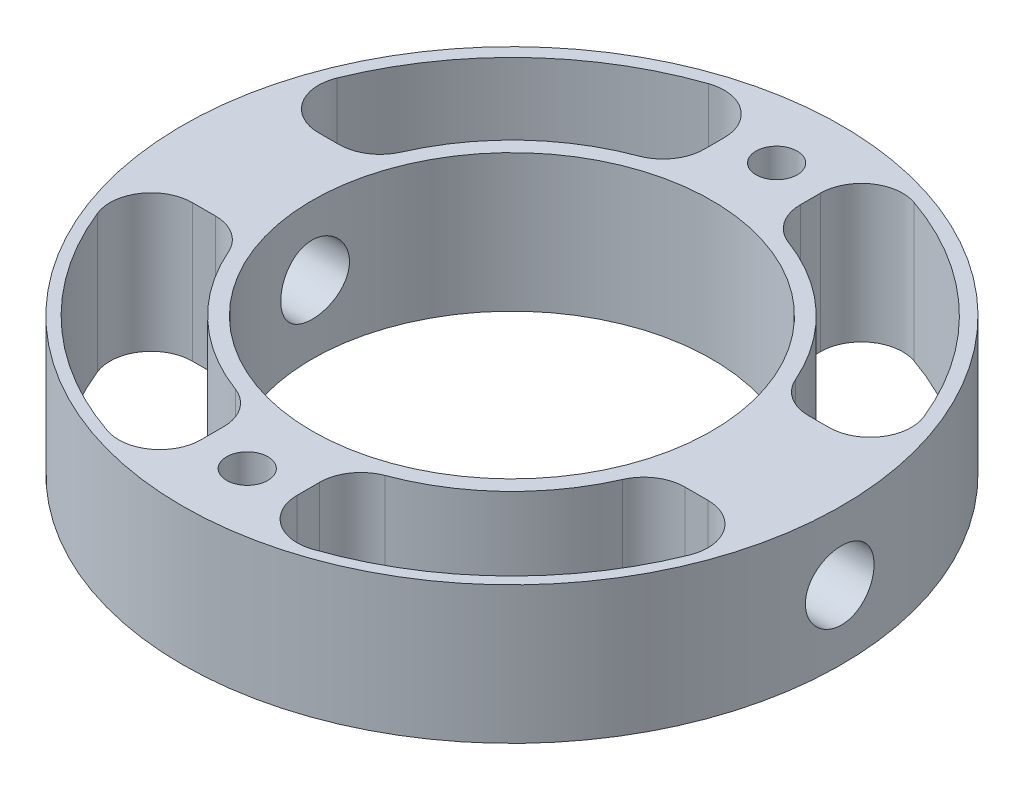
from build123d import *

# Parameters (mm, degrees)
SKETCH3_R           = 24
SKETCH3_R_2         = 14.55
BOSS_EXTRUDE1_DEPTH = 10
CUT_EXTRUDE2_START  = 50
SKETCH4_R           = 2.5
CUT_EXTRUDE2_DEPTH  = 100
SKETCH5_R           = 1.5
CUT_EXTRUDE3_DEPTH  = 100
CUT_EXTRUDE6_DEPTH  = 26
CUT_EXTRUDE7_DEPTH  = 26
CUT_EXTRUDE8_DEPTH  = 26
CUT_EXTRUDE9_DEPTH  = 26
FILLET5_R           = 3


with BuildPart() as part:
    # Sketch3 → Boss-Extrude1 (new body)
    with BuildSketch(Plane(origin=(0, 0, 0), x_dir=(1, 0, 0), z_dir=(0, 1, 0))):
        Circle(SKETCH3_R)
        Circle(SKETCH3_R_2, mode=Mode.SUBTRACT)
    extrude(amount=BOSS_EXTRUDE1_DEPTH)

    # Sketch4 → Cut-Extrude2 (cut)
    with BuildSketch(Plane(origin=(0, 0, 0), x_dir=(0, 0, -1), z_dir=(1, 0, 0)).offset(CUT_EXTRUDE2_START)):
        with Locations((0, 5)):
            Circle(SKETCH4_R)
    extrude(amount=-CUT_EXTRUDE2_DEPTH, mode=Mode.SUBTRACT)

    # Sketch5 → Cut-Extrude3 (cut)
    with BuildSketch(Plane(origin=(0, 10, 0), x_dir=(1, 0, 0), z_dir=(0, 1, 0))):
        with Locations((0, 19.275)):
            Circle(SKETCH5_R)
        with Locations((0, -19.275)):
            Circle(SKETCH5_R)
    extrude(amount=-CUT_EXTRUDE3_DEPTH, mode=Mode.SUBTRACT)

    # Sketch7 → Cut-Extrude6 (cut)
    with BuildSketch(Plane(origin=(0, 10, 0), x_dir=(1, 0, 0), z_dir=(0, 1, 0))):
        with BuildLine():
            Line((3.5, 15.275), (3.5, 22.775))
            ThreePointArc((3.5, 22.775), (15.930450829, 16.648464235), (22.598686356, 4.5))
            Line((22.598686356, 4.5), (15.010850242, 4.5))
            ThreePointArc((15.010850242, 4.5), (10.709250694, 11.440610761), (3.5, 15.275))
        make_face()
    extrude(amount=-CUT_EXTRUDE6_DEPTH, mode=Mode.SUBTRACT)

    # Sketch9 → Cut-Extrude7 (cut)
    with BuildSketch(Plane(origin=(0, 10, 0), x_dir=(1, 0, 0), z_dir=(0, 1, 0))):
        with BuildLine():
            Line((15.010850242, -4.5), (22.775, -4.5))
            ThreePointArc((22.775, -4.5), (16.052855024, -16.770702746), (3.5, -22.94995915))
            Line((3.5, -22.94995915), (3.5, -15.275))
            ThreePointArc((3.5, -15.275), (10.709250694, -11.440610761), (15.010850242, -4.5))
        make_face()
    extrude(amount=-CUT_EXTRUDE7_DEPTH, mode=Mode.SUBTRACT)

    # Sketch10 → Cut-Extrude8 (cut)
    with BuildSketch(Plane(origin=(0, 10, 0), x_dir=(1, 0, 0), z_dir=(0, 1, 0))):
        with BuildLine():
            Line((-3.5, 15.275), (-3.5, 22.775))
            ThreePointArc((-3.5, 22.775), (-15.930450829, 16.648464235), (-22.598686356, 4.5))
            Line((-22.598686356, 4.5), (-15.010850242, 4.5))
            ThreePointArc((-15.010850242, 4.5), (-10.709250694, 11.440610761), (-3.5, 15.275))
        make_face()
    extrude(amount=-CUT_EXTRUDE8_DEPTH, mode=Mode.SUBTRACT)

    # Sketch11 → Cut-Extrude9 (cut)
    with BuildSketch(Plane(origin=(0, 10, 0), x_dir=(1, 0, 0), z_dir=(0, 1, 0))):
        with BuildLine():
            Line((-15.010850242, -4.5), (-22.775, -4.5))
            ThreePointArc((-22.775, -4.5), (-16.052855024, -16.770702746), (-3.5, -22.94995915))
            Line((-3.5, -22.94995915), (-3.5, -15.275))
            ThreePointArc((-3.5, -15.275), (-10.709250694, -11.440610761), (-15.010850242, -4.5))
        make_face()
    extrude(amount=-CUT_EXTRUDE9_DEPTH, mode=Mode.SUBTRACT)

    # Fillet5
    fillet5_edges = [part.edges().sort_by_distance(p)[0] for p in [
        (-3.5, 5, 22.94995915),
        (-22.775, 5, 4.5),
        (-15.010850242, 5, 4.5),
        (-3.5, 5, 15.275),
        (3.5, 5, -22.775),
        (22.598686356, 5, -4.5),
        (15.010850242, 5, -4.5),
        (3.5, 5, -15.275),
        (3.5, 5, 15.275),
        (15.010850242, 5, 4.5),
        (22.775, 5, 4.5),
        (3.5, 5, 22.94995915),
        (-3.5, 5, -15.275),
        (-15.010850242, 5, -4.5),
        (-22.598686356, 5, -4.5),
        (-3.5, 5, -22.775),
    ]]
    fillet(fillet5_edges, radius=FILLET5_R)


solid = part.part
